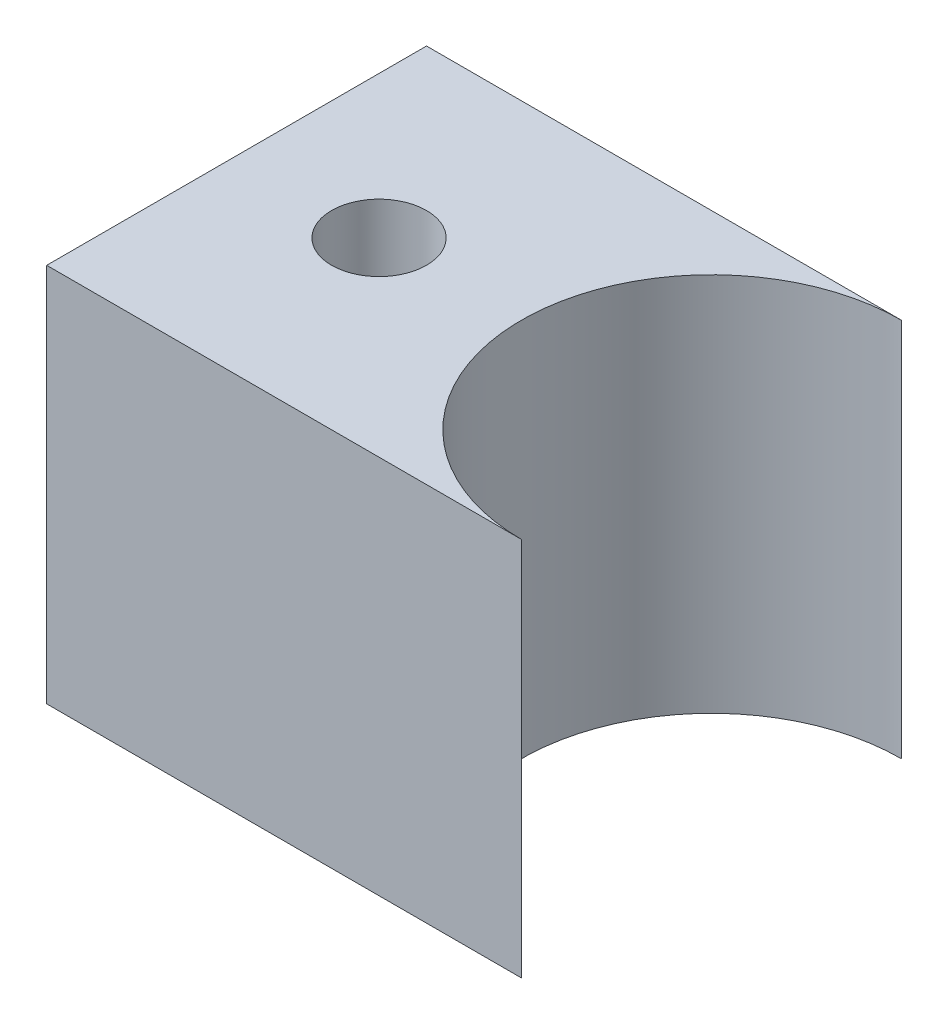
from build123d import *

# Parameters (mm, degrees)
SKETCH2_R           = 3.175
BOSS_EXTRUDE2_DEPTH = 25.4
SKETCH3_R           = 4.7625
CUT_EXTRUDE1_DEPTH  = 14.2875


with BuildPart() as part:
    # Sketch2 → Boss-Extrude2 (new body)
    with BuildSketch(Plane(origin=(0, 0, 0), x_dir=(1, 0, 0), z_dir=(0, 1, 0))):
        with BuildLine():
            Line((-15.875, 12.7), (-15.875, -12.7))
            Line((-15.875, -12.7), (15.875, -12.7))
            ThreePointArc((15.875, -12.7), (3.175, 0), (15.875, 12.7))
            Line((15.875, 12.7), (-15.875, 12.7))
        make_face()
        with Locations((-6.35, 0)):
            Circle(SKETCH2_R, mode=Mode.SUBTRACT)
    extrude(amount=BOSS_EXTRUDE2_DEPTH)

    # Sketch3 → Cut-Extrude1 (cut)
    with BuildSketch(Plane.ZY.offset(15.875)):
        with Locations((0, 12.7)):
            Circle(SKETCH3_R)
    extrude(amount=-CUT_EXTRUDE1_DEPTH, mode=Mode.SUBTRACT)


solid = part.part
